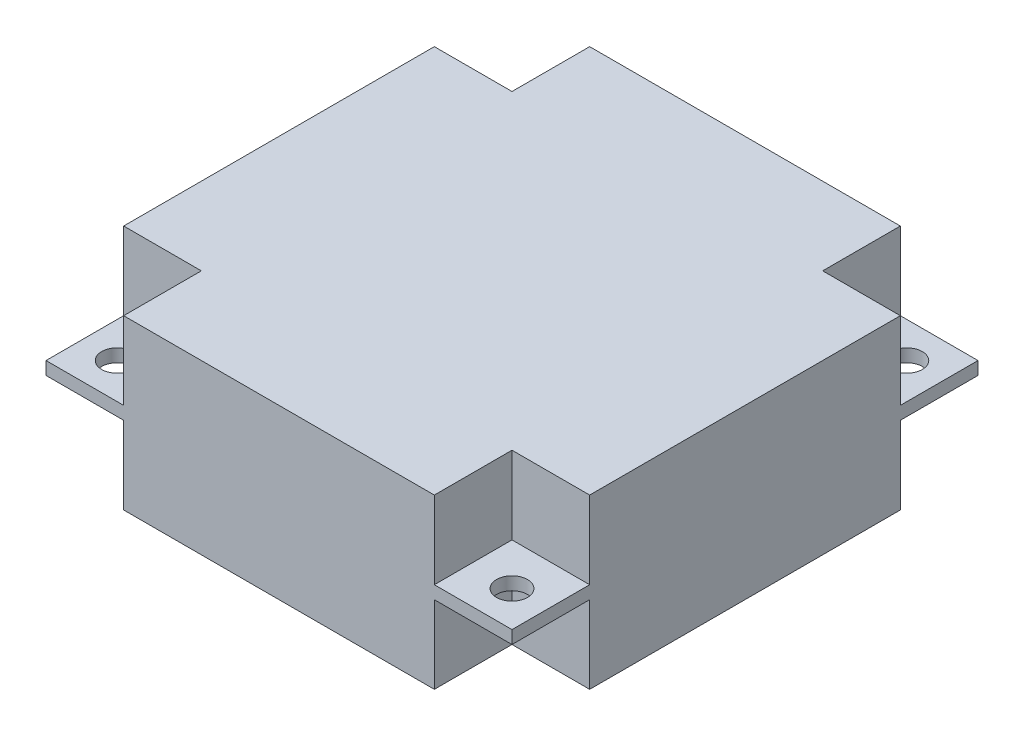
from build123d import *

# Parameters (mm, degrees)
ESQUISSE1_W             = 36
ESQUISSE1_H             = 36
BOSS_EXTRU_1_DEPTH      = 1
D_GAGEMENT_M21_D        = 2.4
ESQUISSE5_W             = 6
ESQUISSE5_H             = 24
ESQUISSE5_W_2           = 24
ESQUISSE5_H_2           = 6
BOSS_EXTRU_2_DEPTH      = 6
BOSS_EXTRU_2_DEPTH_BACK = 7


with BuildPart() as part:
    # Esquisse1 → Boss.-Extru.1 (new body)
    with BuildSketch(Plane(origin=(0, 0, 0), x_dir=(1, 0, 0), z_dir=(0, 1, 0))):
        with Locations((18, 18)):
            Rectangle(ESQUISSE1_W, ESQUISSE1_H)
    extrude(amount=BOSS_EXTRU_1_DEPTH)

    # Dégagement M21 (through all)
    with Locations(Plane(origin=(0, 1, 0), x_dir=(1, 0, 0), z_dir=(0, 1, 0))):
        with Locations((2.75, 2.75), (2.75, 33.25), (33.25, 33.25), (33.25, 2.75)):
            Hole(D_GAGEMENT_M21_D / 2)

    # Esquisse5 → Boss.-Extru.2 (add, two sides)
    with BuildSketch(Plane(origin=(0, 1, 0), x_dir=(1, 0, 0), z_dir=(0, 1, 0))) as boss_extru_2_sk:
        with Locations((3, 18)):
            Rectangle(ESQUISSE5_W, ESQUISSE5_H)
        with Locations((18, 18)):
            Rectangle(ESQUISSE5_W_2, ESQUISSE5_H)
        with Locations((18, 33)):
            Rectangle(ESQUISSE5_W_2, ESQUISSE5_H_2)
        with Locations((33, 18)):
            Rectangle(ESQUISSE5_W, ESQUISSE5_H)
        with Locations((18, 3)):
            Rectangle(ESQUISSE5_W_2, ESQUISSE5_H_2)
    extrude(amount=BOSS_EXTRU_2_DEPTH)
    extrude(boss_extru_2_sk.sketch, amount=-BOSS_EXTRU_2_DEPTH_BACK)


solid = part.part
